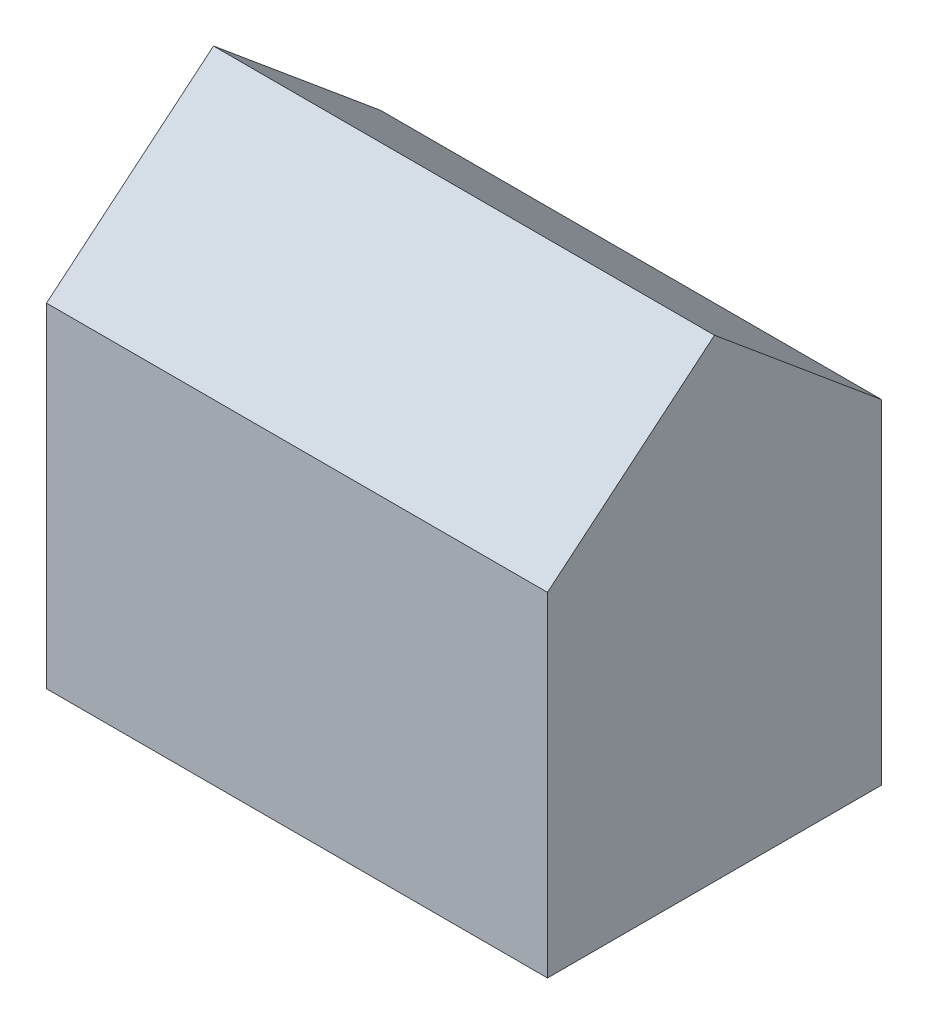
from build123d import *

# Parameters (mm, degrees)
SKETCH1_W           = 18
SKETCH1_H           = 12
SKETCH1_W_2         = 14
SKETCH1_H_2         = 8
BOSS_EXTRUDE1_DEPTH = 12
BOSS_EXTRUDE2_DEPTH = 18


with BuildPart() as part:
    # Sketch1 → Boss-Extrude1 (new body)
    with BuildSketch(Plane(origin=(0, 0, 0), x_dir=(1, 0, 0), z_dir=(0, 1, 0))):
        with Locations((9, 6)):
            Rectangle(SKETCH1_W, SKETCH1_H)
        with Locations((9, 6)):
            Rectangle(SKETCH1_W_2, SKETCH1_H_2, mode=Mode.SUBTRACT)
    extrude(amount=BOSS_EXTRUDE1_DEPTH)

    # Sketch2 → Boss-Extrude2 (add)
    with BuildSketch(Plane(origin=(18, 0, 0), x_dir=(0, 0, -1), z_dir=(1, 0, 0))):
        Polygon((6, 17), (0, 12), (12, 12), align=None)
    extrude(amount=-BOSS_EXTRUDE2_DEPTH)


solid = part.part
